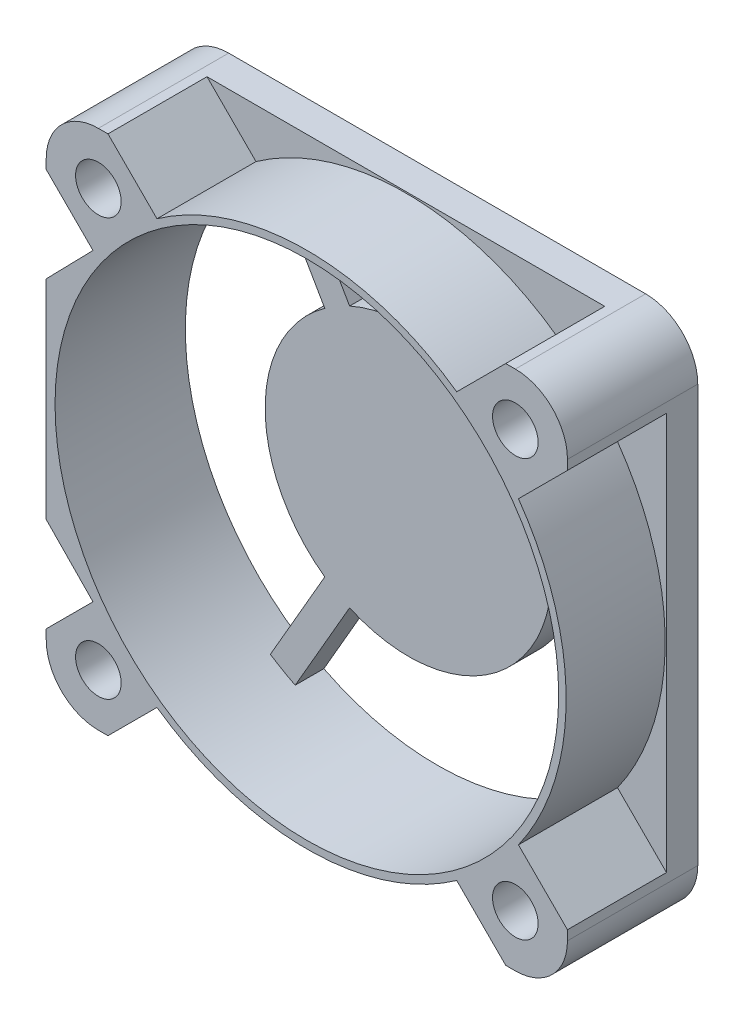
from build123d import *

# Parameters (mm, degrees)
SKETCH21_W          = 40
SKETCH21_H          = 40
BOSS_EXTRUDE4_DEPTH = 5
FILLET3_R           = 4
SKETCH22_R          = 19.325
CUT_EXTRUDE11_DEPTH = 11
CUT_EXTRUDE12_DEPTH = 7.6
SKETCH30_R          = 1.75
CUT_EXTRUDE13_DEPTH = 10
CIRPATTERN2_COUNT   = 4
BOSS_EXTRUDE3_DEPTH = 2.2
BOSS_EXTRUDE5_REACH = 12


with BuildPart() as part:
    # Sketch21 → Boss-Extrude4 (new body, symmetric)
    with BuildSketch(Plane.XY):
        Rectangle(SKETCH21_W, SKETCH21_H)
    extrude(amount=BOSS_EXTRUDE4_DEPTH, both=True)

    # Fillet3
    fillet3_edges = [part.edges().sort_by_distance(p)[0] for p in [
        (20, -20, 0),
        (-20, -20, 0),
        (-20, 20, 0),
        (20, 20, 0),
    ]]
    fillet(fillet3_edges, radius=FILLET3_R)

    # Sketch22 → Cut-Extrude11 (cut, through all)
    with BuildSketch(Plane.XY.offset(5)):
        Circle(SKETCH22_R)
    extrude(amount=-CUT_EXTRUDE11_DEPTH, mode=Mode.SUBTRACT)

    # Sketch23 → Cut-Extrude12 (cut)
    with BuildSketch(Plane.XY.offset(5)):
        with BuildLine():
            Line((15.262384566, 20), (11.501799696, 16.23941513))
            ThreePointArc((11.501799696, 16.23941513), (0, 19.9), (-11.501799696, 16.23941513))
            Line((-11.501799696, 16.23941513), (-15.262384566, 20))
            Line((-15.262384566, 20), (15.262384566, 20))
        make_face()
    cut_extrude12 = extrude(amount=-CUT_EXTRUDE12_DEPTH, mode=Mode.SUBTRACT)

    # Sketch30 → Cut-Extrude13 (cut)
    with BuildSketch(Plane.XY.offset(5)):
        with Locations((-16, 16)):
            Circle(SKETCH30_R)
    cut_extrude13 = extrude(amount=-CUT_EXTRUDE13_DEPTH, mode=Mode.SUBTRACT)

    # CirPattern2: Cut-Extrude12, Cut-Extrude13 ×4 about axis
    cirpattern2_axis = Axis((0, 0, 0), (0, 0, 1))
    for i in range(1, CIRPATTERN2_COUNT):
        add(cut_extrude12.rotate(cirpattern2_axis, i * 360 / CIRPATTERN2_COUNT), mode=Mode.SUBTRACT)
        add(cut_extrude13.rotate(cirpattern2_axis, i * 360 / CIRPATTERN2_COUNT), mode=Mode.SUBTRACT)

    # Sketch20 → Boss-Extrude3 (add)
    with BuildSketch(Plane(origin=(0, 0, -5), x_dir=(-1, 0, 0), z_dir=(0, 0, -1))):
        with BuildLine():
            Line((6.425058848, 8.928528367), (10.599461946, 16.158806623))
            ThreePointArc((10.599461946, 16.158806623), (9.6625, 16.735940928), (8.694206057, 17.258806623))
            Line((8.694206057, 17.258806623), (4.51980296, 10.028528367))
            ThreePointArc((4.51980296, 10.028528367), (-5.5, 9.526279442), (-10.944861808, 1.1))
            Line((-10.944861808, 1.1), (-19.293668003, 1.1))
            ThreePointArc((-19.293668003, 1.1), (-19.325, 0), (-19.293668003, -1.1))
            Line((-19.293668003, -1.1), (-10.944861808, -1.1))
            ThreePointArc((-10.944861808, -1.1), (-5.5, -9.526279442), (4.51980296, -10.028528367))
            Line((4.51980296, -10.028528367), (8.694206057, -17.258806623))
            ThreePointArc((8.694206057, -17.258806623), (9.6625, -16.735940928), (10.599461946, -16.158806623))
            Line((10.599461946, -16.158806623), (6.425058848, -8.928528367))
            ThreePointArc((6.425058848, -8.928528367), (11, 0), (6.425058848, 8.928528367))
        make_face()
    extrude(amount=-BOSS_EXTRUDE3_DEPTH)

    # Sketch31 → Boss-Extrude5 (add, up to next)
    with BuildSketch(Plane.XY.offset(5), mode=Mode.PRIVATE) as boss_extrude5_sk1:
        with BuildLine():
            Line((-14.240301081, 13.900497298), (-20, 8))
            Line((-20, 8), (-20, -8))
            Line((-20, -8), (-14.240301081, -13.900497298))
            ThreePointArc((-14.240301081, -13.900497298), (-19.9, 0), (-14.240301081, 13.900497298))
        make_face()
    boss_extrude5_tool1 = extrude(boss_extrude5_sk1.sketch, amount=-BOSS_EXTRUDE5_REACH, mode=Mode.PRIVATE) - part.part
    add(boss_extrude5_tool1.solids().sort_by_distance((-19.928391, 0, 5))[0])


solid = part.part
